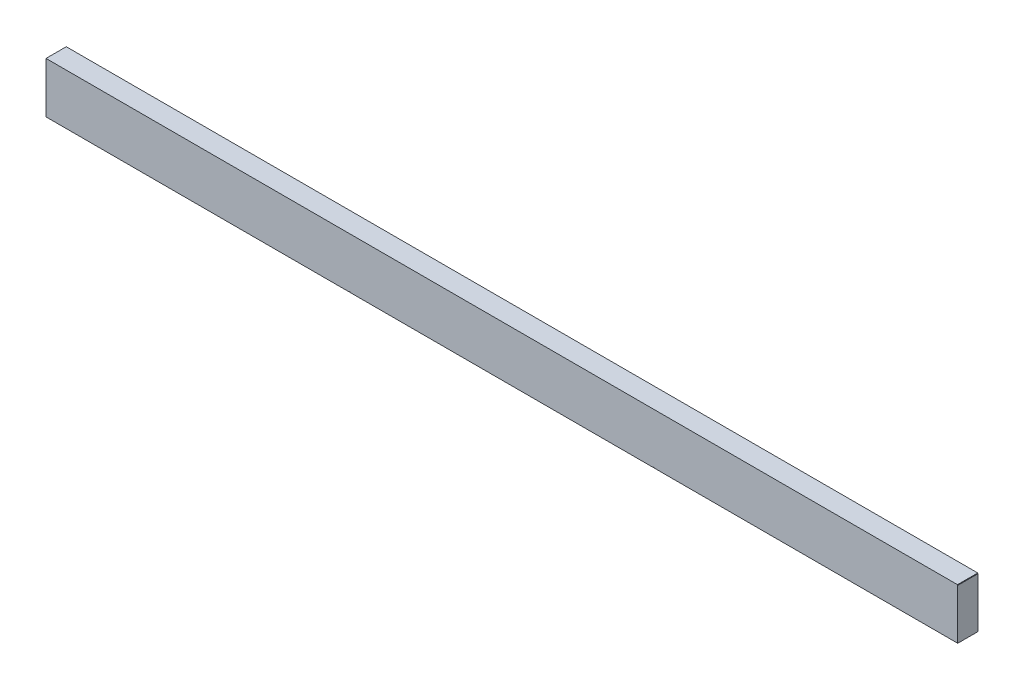
from build123d import *

# Parameters (mm, degrees)
SKETCH1_W           = 200
SKETCH1_H           = 500
BOSS_EXTRUDE1_DEPTH = 9000
SKETCH2_W           = 5
SKETCH2_H           = 10
CUT_EXTRUDE1_DEPTH  = 201


with BuildPart() as part:
    # Sketch1 → Boss-Extrude1 (new body)
    with BuildSketch(Plane(origin=(0, 0, 0), x_dir=(0, 0, -1), z_dir=(1, 0, 0))):
        Rectangle(SKETCH1_W, SKETCH1_H)
    extrude(amount=BOSS_EXTRUDE1_DEPTH)

    # Sketch2 → Cut-Extrude1 (cut, through all)
    with BuildSketch(Plane.XY.offset(100)):
        with Locations((3000, -250)):
            Rectangle(SKETCH2_W, SKETCH2_H)
        with Locations((6000, -250)):
            Rectangle(SKETCH2_W, SKETCH2_H)
        with Locations((9000, 250)):
            Rectangle(SKETCH2_W, SKETCH2_H)
    extrude(amount=-CUT_EXTRUDE1_DEPTH, mode=Mode.SUBTRACT)


solid = part.part
